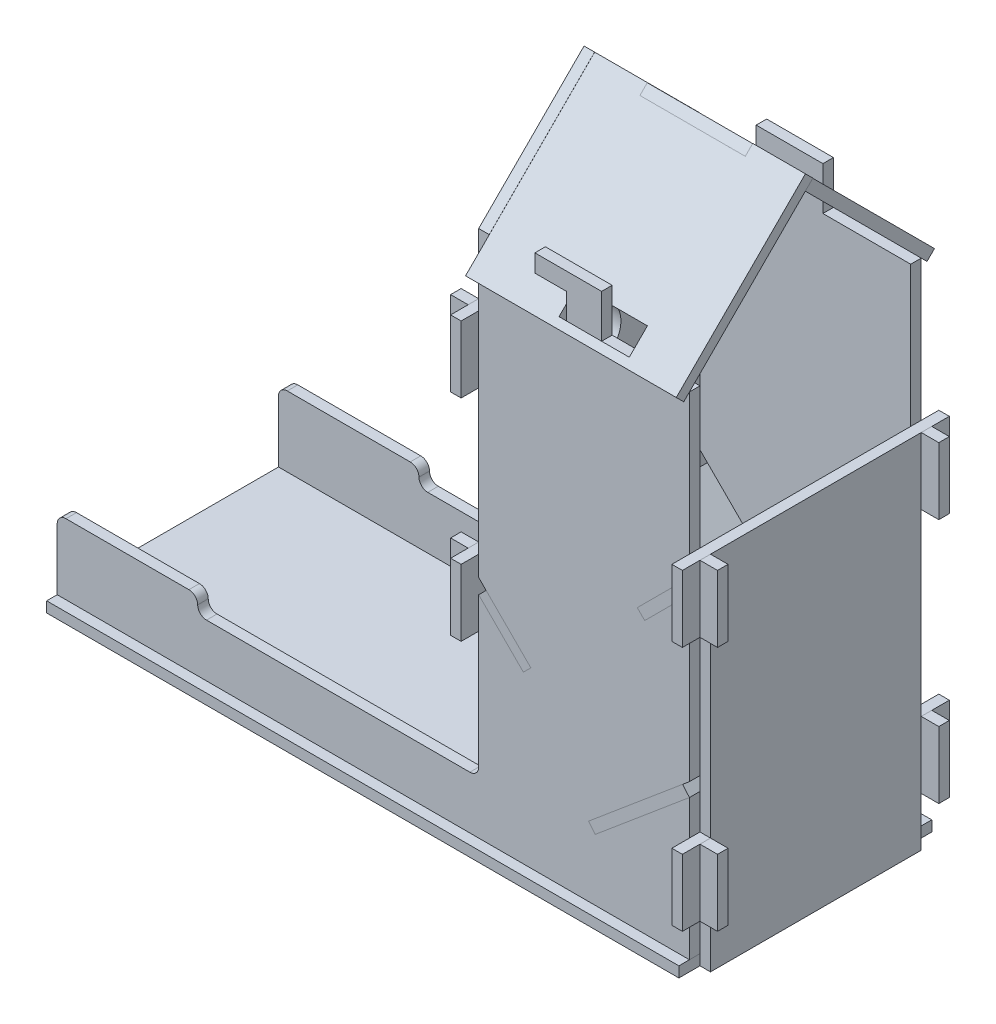
from build123d import *

# Parameters (mm, degrees)
EXTRUDE_1_DEPTH          = 66
SKETCH_2_W               = 60
SKETCH_2_H               = 205.231361782
CUT_EXTRUDE_1_DEPTH      = 9
CUT_EXTRUDE_1_DEPTH_BACK = 181
SKETCH_3_W               = 180
SKETCH_3_H               = 72
SKETCH_3_W_2             = 20
SKETCH_3_H_2             = 3
EXTRUDE_5_DEPTH          = 3
EXTRUDE_7_DEPTH          = 3
EXTRUDE_8_DEPTH          = 3
EXTRUDE_10_DEPTH         = 3
EXTRUDE_11_DEPTH         = 3
SKETCH_10_R              = 7.5
EXTRUDE_12_DEPTH         = 3
SKETCH_11_W              = 20
SKETCH_11_H              = 7.3
EXTRUDE_13_DEPTH         = 3
SKETCH_12_W              = 20
SKETCH_12_H              = 7.3
EXTRUDE_14_DEPTH         = 3


with BuildPart() as part:
    # 草图1 → 凸台-拉伸1 (new body)
    with BuildSketch(Plane.XY):
        with BuildLine():
            Line((-160, 0), (-160, -5.5))
            Line((-160, -5.5), (-141, -5.5))
            Line((-141, -5.5), (-141, -3))
            Line((-141, -3), (-150, -3))
            Line((-150, -3), (-150, 0))
            Line((-150, 0), (-40, 0))
            Line((-40, 0), (-40, -5.5))
            Line((-40, -5.5), (-21, -5.5))
            Line((-21, -5.5), (-21, -3))
            Line((-21, -3), (-30, -3))
            Line((-30, -3), (-30, 0))
            Line((-30, 0), (0, 0))
            Line((0, 0), (0, 11))
            Line((0, 11), (8, 11))
            Line((8, 11), (8, 30))
            Line((8, 30), (3, 30))
            Line((3, 30), (3, 20))
            Line((3, 20), (0, 20))
            Line((0, 20), (0, 40))
            Line((0, 40), (-26.811555509, 17.502433661))
            Line((-26.811555509, 17.502433661), (-28.739918338, 19.80056699))
            Line((-28.739918338, 19.80056699), (0, 43.916221868))
            Line((0, 43.916221868), (0, 81))
            Line((0, 81), (8, 81))
            Line((8, 81), (8, 100))
            Line((8, 100), (3, 100))
            Line((3, 100), (3, 90))
            Line((3, 90), (0, 90))
            Line((0, 90), (-12.727922061, 77.272077939))
            Line((-12.727922061, 77.272077939), (-14.849242405, 79.393398282))
            Line((-14.849242405, 79.393398282), (0, 94.242640687))
            Line((0, 94.242640687), (0, 140))
            Line((0, 140), (-25, 140))
            Line((-25, 140), (-25, 152.3))
            Line((-25, 152.3), (-44, 152.3))
            Line((-44, 152.3), (-44, 147.3))
            Line((-44, 147.3), (-35, 147.3))
            Line((-35, 147.3), (-35, 140))
            Line((-35, 140), (-60, 140))
            Line((-60, 140), (-60, 120))
            Line((-60, 120), (-63, 120))
            Line((-63, 120), (-63, 130))
            Line((-63, 130), (-68, 130))
            Line((-68, 130), (-68, 111))
            Line((-68, 111), (-60, 111))
            Line((-60, 111), (-60, 64.242640687))
            Line((-60, 64.242640687), (-45.150757595, 49.393398282))
            Line((-45.150757595, 49.393398282), (-47.272077939, 47.272077939))
            Line((-47.272077939, 47.272077939), (-60, 60))
            Line((-60, 60), (-63, 60))
            Line((-63, 60), (-63, 70))
            Line((-63, 70), (-68, 70))
            Line((-68, 70), (-68, 51))
            Line((-68, 51), (-60, 51))
            Line((-60, 51), (-60, 17.5))
            ThreePointArc((-60, 17.5), (-60.732233047, 15.732233047), (-62.5, 15))
            Line((-62.5, 15), (-137.5, 15))
            ThreePointArc((-137.5, 15), (-139.267766953, 15.732233047), (-140, 17.5))
            ThreePointArc((-140, 17.5), (-140.732233047, 19.267766953), (-142.5, 20))
            Line((-142.5, 20), (-177.5, 20))
            ThreePointArc((-177.5, 20), (-179.267766953, 19.267766953), (-180, 17.5))
            Line((-180, 17.5), (-180, 0))
            Line((-180, 0), (-160, 0))
        make_face()
    extrude(amount=-EXTRUDE_1_DEPTH)

    # 草图2 → 切除-拉伸1 (cut, two sides)
    with BuildSketch(Plane(origin=(0, 0, 0), x_dir=(0, 0, -1), z_dir=(1, 0, 0))) as cut_extrude_1_sk:
        with Locations((33, 64.463069047)):
            Rectangle(SKETCH_2_W, SKETCH_2_H)
    extrude(amount=CUT_EXTRUDE_1_DEPTH, mode=Mode.SUBTRACT)
    extrude(cut_extrude_1_sk.sketch, amount=-CUT_EXTRUDE_1_DEPTH_BACK, mode=Mode.SUBTRACT)


with BuildPart() as body_2:
    # 草图3 → 凸台-拉伸5 (new body)
    with BuildSketch(Plane.XZ):
        with Locations((-90, -33)):
            Rectangle(SKETCH_3_W, SKETCH_3_H)
        with Locations((-160, -1.5)):
            Rectangle(SKETCH_3_W_2, SKETCH_3_H_2, mode=Mode.SUBTRACT)
        with Locations((-40, -1.5)):
            Rectangle(SKETCH_3_W_2, SKETCH_3_H_2, mode=Mode.SUBTRACT)
        with Locations((-40, -64.5)):
            Rectangle(SKETCH_3_W_2, SKETCH_3_H_2, mode=Mode.SUBTRACT)
        with Locations((-160, -64.5)):
            Rectangle(SKETCH_3_W_2, SKETCH_3_H_2, mode=Mode.SUBTRACT)
    extrude(amount=EXTRUDE_5_DEPTH)


with BuildPart() as body_3:
    # 草图6 → 凸台-拉伸7 (new body)
    with BuildSketch(Plane(origin=(0, 0, 0), x_dir=(0, 0, -1), z_dir=(1, 0, 0))):
        Polygon((3, 100), (-5, 100), (-5, 81), (0, 81), (0, 90), (3, 90), (3, 30), (-5, 30), (-5, 11), (0, 11), (0, 20), (3, 20), (3, -3), (63, -3), (63, 20), (66, 20), (66, 11), (71, 11), (71, 30), (63, 30), (63, 90), (66, 90), (66, 81), (71, 81), (71, 100), (66, 100), (63, 100), align=None)
    extrude(amount=EXTRUDE_7_DEPTH)


with BuildPart() as body_4:
    # 草图7 → 凸台-拉伸8 (new body)
    with BuildSketch(Plane(origin=(-45, 45, 0), x_dir=(0, 0, 1), z_dir=(-0.707106781, 0.707106781, 0))):
        Polygon((-3, 45.639610307), (0, 45.639610307), (0, 63.639610307), (-3, 63.639610307), (-63, 63.639610307), (-66, 63.639610307), (-66, 45.639610307), (-63, 45.639610307), (-63, 37.639610307), (-3, 37.639610307), align=None)
    extrude(amount=EXTRUDE_8_DEPTH)


with BuildPart() as body_5:
    # 草图8 → 凸台-拉伸10 (new body)
    with BuildSketch(Plane(origin=(0, 0, 0), x_dir=(0, 0, -1), z_dir=(0.707106781, 0.707106781, 0))):
        Polygon((63, 84.852813742), (66, 84.852813742), (66, 66.852813742), (63, 66.852813742), (63, 58.852813742), (3, 58.852813742), (3, 66.852813742), (0, 66.852813742), (0, 84.852813742), (3, 84.852813742), align=None)
    extrude(amount=EXTRUDE_10_DEPTH)


with BuildPart() as body_6:
    # 草图9 → 凸台-拉伸11 (new body)
    with BuildSketch(Plane(origin=(-19.69615506, 23.472963553, 0), x_dir=(0.766044443, 0.64278761, 0), z_dir=(-0.64278761, 0.766044443, 0))):
        Polygon((25.711504387, 3), (25.711504387, 0), (-9.288495613, 0), (-9.288495613, 3), (-32.288495613, 3), (-32.288495613, 63), (-9.288495613, 63), (-9.288495613, 66), (25.711504387, 66), (25.711504387, 63), align=None)
    extrude(amount=EXTRUDE_11_DEPTH)


with BuildPart() as body_7:
    # 草图10 → 凸台-拉伸12 (new body)
    with BuildSketch(Plane.ZY.offset(60)):
        Polygon((-3, 120), (0, 120), (0, 111), (5, 111), (5, 130), (-3, 130), (-3, 147.3), (-33, 177.3), (-63, 147.3), (-63, 130), (-71, 130), (-71, 111), (-66, 111), (-66, 120), (-63, 120), (-63, 70), (-71, 70), (-71, 51), (-66, 51), (-66, 60), (-63, 60), (-63, 40), (-3, 40), (-3, 60), (0, 60), (0, 51), (5, 51), (5, 70), (-3, 70), align=None)
        with Locations((-33, 137.3)):
            Circle(SKETCH_10_R, mode=Mode.SUBTRACT)
        with Locations((-33, 107.3)):
            Circle(SKETCH_10_R, mode=Mode.SUBTRACT)
    extrude(amount=EXTRUDE_12_DEPTH)


with BuildPart() as body_8:
    # 草图11 → 凸台-拉伸13 (new body)
    with BuildSketch(Plane(origin=(0, 70, 70), x_dir=(-1, 0, 0), z_dir=(0, 0.707106781, 0.707106781))):
        Polygon((60, -148.704556084), (45, -148.704556084), (45, -145.704556084), (15, -145.704556084), (15, -148.704556084), (0, -148.704556084), (0, -96.704556084), (60, -96.704556084), align=None)
        with Locations((25, -102.644949366)):
            Rectangle(SKETCH_11_W, SKETCH_11_H, mode=Mode.SUBTRACT)
    extrude(amount=EXTRUDE_13_DEPTH)


with BuildPart() as body_9:
    # 草图12 → 凸台-拉伸14 (new body)
    with BuildSketch(Plane(origin=(0, 103, -103), x_dir=(-1, 0, 0), z_dir=(0, 0.707106781, -0.707106781))):
        Polygon((15, 101.994949366), (45, 101.994949366), (45, 98.994949366), (60, 98.994949366), (60, 49.994949366), (0, 49.994949366), (0, 98.994949366), (15, 98.994949366), align=None)
        with Locations((25, 55.975901808)):
            Rectangle(SKETCH_12_W, SKETCH_12_H, mode=Mode.SUBTRACT)
    extrude(amount=EXTRUDE_14_DEPTH)


solid = Compound([part.part, body_2.part, body_3.part, body_4.part, body_5.part, body_6.part, body_7.part, body_8.part, body_9.part])
